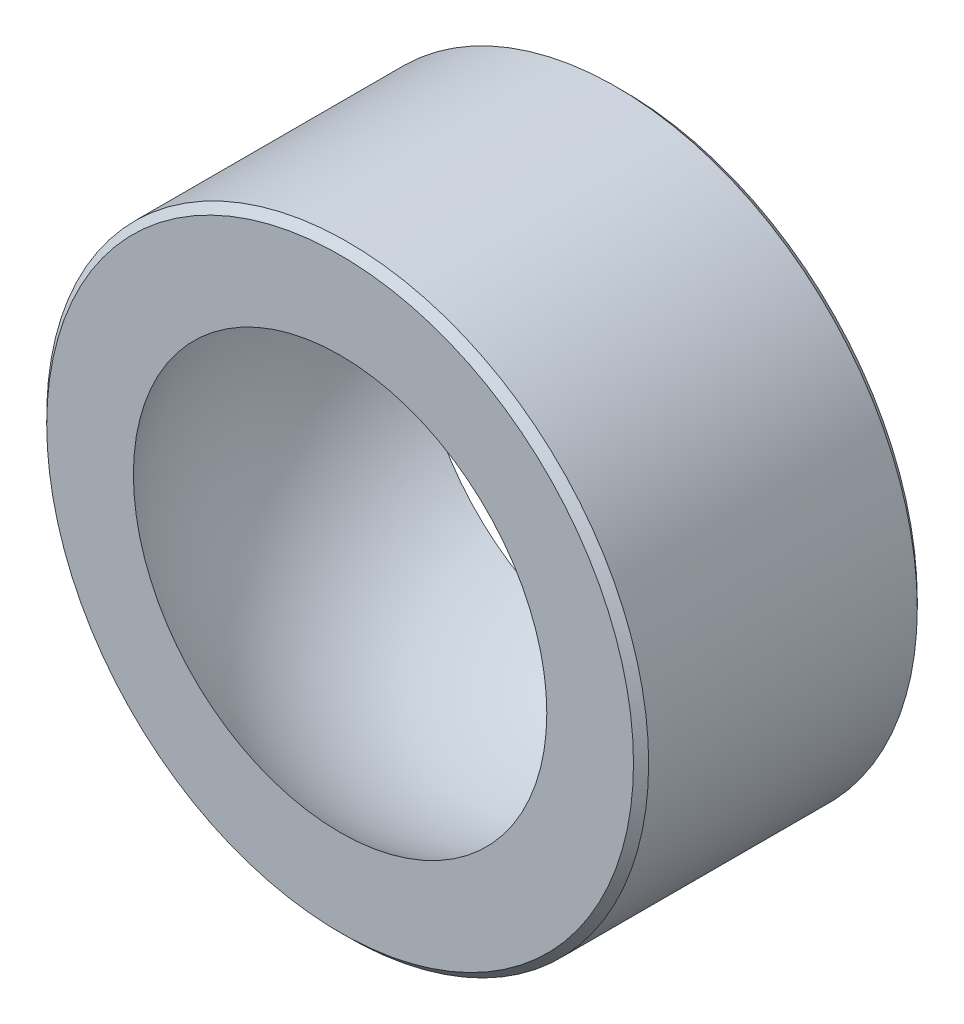
from build123d import *

# Parameters (mm, degrees)
BOSS_EXTRUDE1_DEPTH      = 5.6134
BOSS_EXTRUDE1_DEPTH_BACK = 5.6134
SKETCH1_R                = 11.90625
CHAMFER1_SIZE            = 0.3


with BuildPart() as part:
    # Sketch1 → Boss-Extrude1 (new, two sides: drawn at the far end of the back side and taken through both)
    with BuildSketch(Plane.XY.offset(-BOSS_EXTRUDE1_DEPTH_BACK)):
        Circle(SKETCH1_R)
    extrude(amount=BOSS_EXTRUDE1_DEPTH + BOSS_EXTRUDE1_DEPTH_BACK)

    # Sketch2 → Cut-Revolve1 (revolve, cut)
    with BuildSketch(Plane.XY):
        with BuildLine():
            Line((0, 9.9187), (0, -9.9187))
            ThreePointArc((0, -9.9187), (9.9187, 0), (0, 9.9187))
        make_face()
    revolve(axis=Axis((0, 12.922977109, 0), (0, -1, 0)), mode=Mode.SUBTRACT)

    # Chamfer1
    chamfer1_edges = [part.edges().sort_by_distance(p)[0] for p in [
        (-11.90625, 0, 5.6134),
        (-11.90625, 0, -5.6134),
    ]]
    chamfer(chamfer1_edges, length=CHAMFER1_SIZE)


solid = part.part
